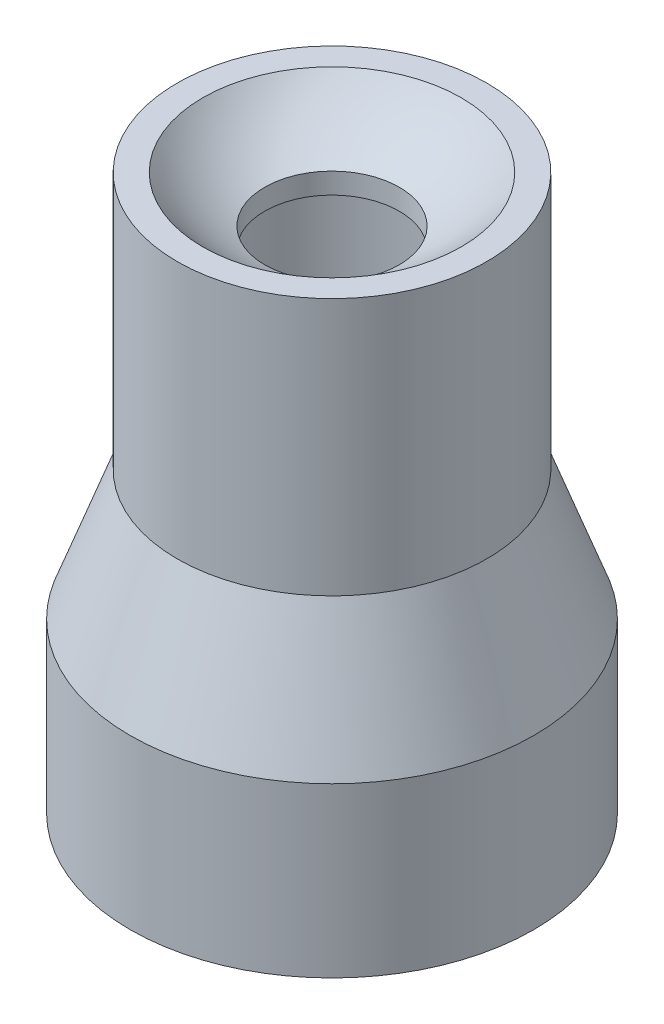
from build123d import *


with BuildPart() as part:
    # Sketch1 → Revolve1 (revolve)
    with BuildSketch(Plane.XY):
        with BuildLine():
            Line((6, 0), (5, 0))
            Line((5, 0), (5, 5))
            Line((5, 5), (3.6, 5))
            Line((3.6, 5), (3.6, 14.5))
            Line((3.6, 14.5), (2, 14.5))
            Line((2, 14.5), (2, 15.117424305))
            ThreePointArc((2, 15.117424305), (3.001625132, 15.701219365), (3.841874542, 16.5))
            Line((3.841874542, 16.5), (4.6, 16.5))
            Line((4.6, 16.5), (4.6, 8.846468387))
            Line((4.6, 8.846468387), (6, 5))
            Line((6, 5), (6, 0))
        make_face()
    revolve(axis=Axis((0, 14.8, 0), (0, -1, 0)))


solid = part.part
